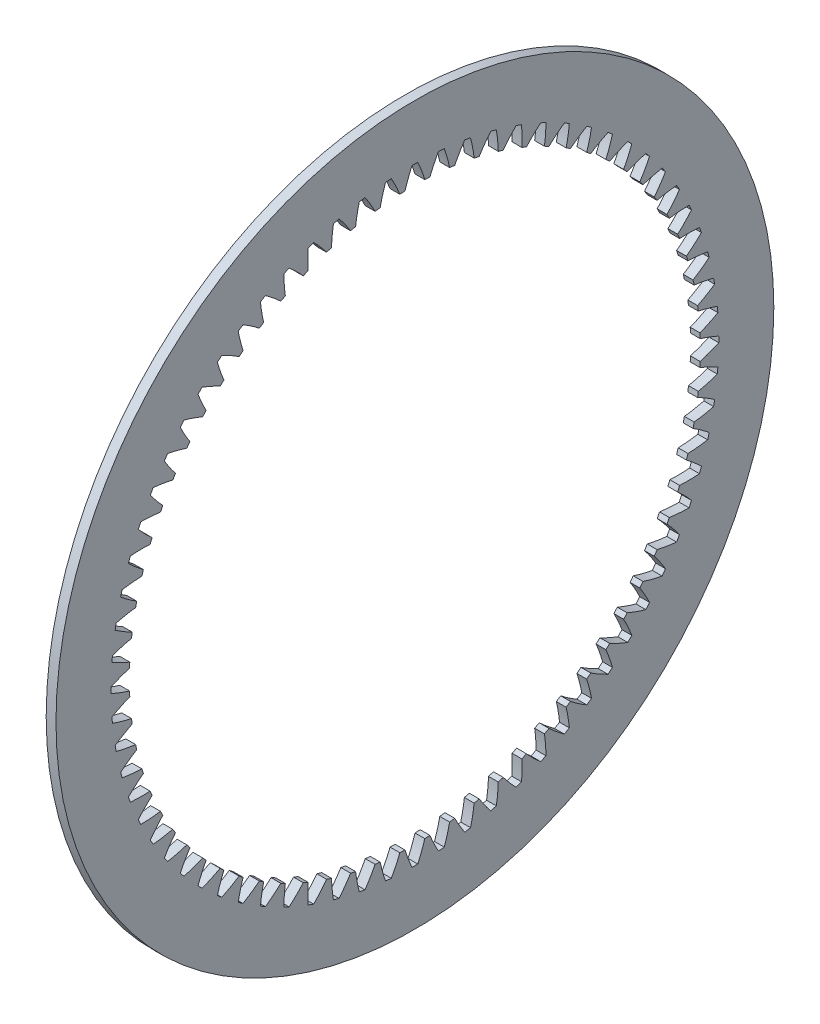
from build123d import *

# Parameters (mm, degrees)
BASPROSKE_W     = 3
BASPROSKE_H     = 22.5
TOOTHCUT_DEPTH  = 156.592416268
TEETHCUTS_COUNT = 72
TEETHCUTS_ANGLE = 355


with BuildPart() as part:
    # BasProSke → Base-Revolve (revolve)
    with BuildSketch(Plane(origin=(0, 0, 0), x_dir=(1, 0, 0), z_dir=(0, 1, 0))):
        with Locations((1.5, 98.75)):
            Rectangle(BASPROSKE_W, BASPROSKE_H)
    revolve(axis=Axis((-10, 0, 0), (1, 0, 0)))

    # TooCutSke → ToothCut (cut, through all)
    with BuildSketch(Plane(origin=(0, 0, 0), x_dir=(0, 0, -1), z_dir=(1, 0, 0))):
        with BuildLine():
            ThreePointArc((3.033698313, 87.421978471), (2.056218708, 90.308270103), (0.885638015, 93.12178865))
            ThreePointArc((0.885638015, 93.12178865), (0, 93.126), (-0.885638015, 93.12178865))
            ThreePointArc((-0.885638015, 93.12178865), (-2.056218708, 90.308270103), (-3.033698313, 87.421978471))
            ThreePointArc((-3.033698313, 87.421978471), (0, 87.4746), (3.033698313, 87.421978471))
        make_face()
    toothcut = extrude(amount=TOOTHCUT_DEPTH, mode=Mode.SUBTRACT)

    # TeethCuts: ToothCut ×72 about axis
    teethcuts_axis = Axis((-10, 0, 0), (1, 0, 0))
    for i in range(1, TEETHCUTS_COUNT):
        add(toothcut.rotate(teethcuts_axis, i * TEETHCUTS_ANGLE / (TEETHCUTS_COUNT - 1)), mode=Mode.SUBTRACT)


solid = part.part
